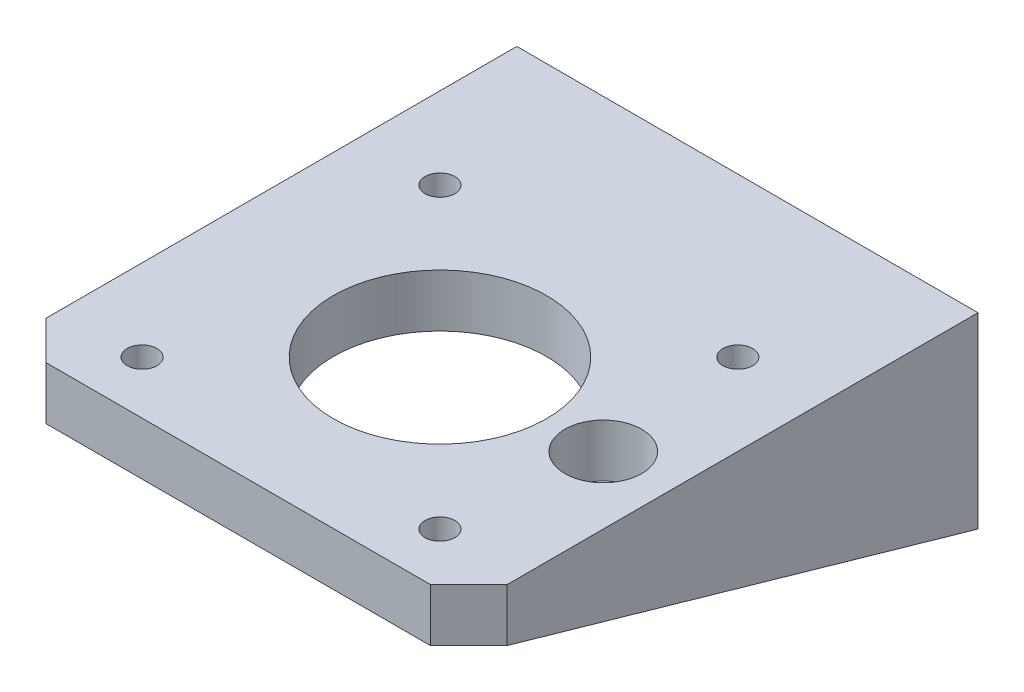
from build123d import *

# Parameters (mm, degrees)
CROQUIS1_R                 = 1.55
CROQUIS1_R_2               = 11.1
CROQUIS1_R_3               = 4
SALIENTE_EXTRUIR1_DEPTH    = 5.5
SALIENTE_EXTRUIR2_DEPTH    = 5.5
SALIENTE_EXTRUIR3_DEPTH    = 3
SALIENTE_EXTRUIR4_DEPTH    = 5.5
SALIENTE_EXTRUIR5_DEPTH    = 3
CROQUIS7_W                 = 42
CROQUIS7_H                 = 9
SALIENTE_EXTRUIR6_DEPTH    = 14
CROQUIS9_R                 = 1.55
CORTAR_EXTRUIR1_DEPTH      = 9
CROQUIS10_R                = 2.85
CROQUIS10_R_2              = 1.55
CORTAR_EXTRUIR2_DEPTH      = 3
CORTAR_EXTRUIR3_DEPTH      = 4
CORTAR_EXTRUIR3_DEPTH_BACK = 46


with BuildPart() as part:
    # Croquis1 → Saliente-Extruir1 (new body)
    with BuildSketch(Plane(origin=(0, 0, 0), x_dir=(1, 0, 0), z_dir=(0, 1, 0))):
        Polygon((0, 4), (0, 49), (4, 53), (44, 53), (48, 49), (48, 4), (44, 0), (4, 0), align=None)
        with Locations((8.5, 36.5)):
            Circle(CROQUIS1_R, mode=Mode.SUBTRACT)
        with Locations((39.5, 36.5)):
            Circle(CROQUIS1_R, mode=Mode.SUBTRACT)
        with Locations((8.5, 5.5)):
            Circle(CROQUIS1_R, mode=Mode.SUBTRACT)
        with Locations((39.5, 5.5)):
            Circle(CROQUIS1_R, mode=Mode.SUBTRACT)
        with Locations((24, 21)):
            Circle(CROQUIS1_R_2, mode=Mode.SUBTRACT)
        with Locations((41, 21)):
            Circle(CROQUIS1_R_3, mode=Mode.SUBTRACT)
    extrude(amount=SALIENTE_EXTRUIR1_DEPTH)

    # Croquis3 → Saliente-Extruir2 (add)
    with BuildSketch(Plane(origin=(0, 5.5, 0), x_dir=(1, 0, 0), z_dir=(0, 1, 0))):
        Polygon((4, 53), (0, 53), (0, 49), align=None)
    extrude(amount=-SALIENTE_EXTRUIR2_DEPTH)

    # Croquis4 → Saliente-Extruir3 (add)
    with BuildSketch(Plane.ZY):
        Polygon((-53, 0), (-53, 5.5), (-4, 5.5), (-4, 0), (-53, -14), align=None)
    extrude(amount=-SALIENTE_EXTRUIR3_DEPTH)

    # Croquis5 → Saliente-Extruir4 (add)
    with BuildSketch(Plane(origin=(0, 5.5, 0), x_dir=(1, 0, 0), z_dir=(0, 1, 0))):
        Polygon((48, 49), (48, 53), (44, 53), align=None)
    extrude(amount=-SALIENTE_EXTRUIR4_DEPTH)

    # Croquis6 → Saliente-Extruir5 (add)
    with BuildSketch(Plane(origin=(48, 0, 0), x_dir=(0, 0, -1), z_dir=(1, 0, 0))):
        Polygon((4, 5.5), (4, 0), (53, -14), (53, 0), (53, 5.5), align=None)
    extrude(amount=-SALIENTE_EXTRUIR5_DEPTH)

    # Croquis7 → Saliente-Extruir6 (add)
    with BuildSketch(Plane.XZ):
        with Locations((24, -48.5)):
            Rectangle(CROQUIS7_W, CROQUIS7_H)
    extrude(amount=SALIENTE_EXTRUIR6_DEPTH)

    # Croquis9 → Cortar-Extruir1 (cut)
    with BuildSketch(Plane.XY.offset(-44)):
        with Locations((9, -5.714285714)):
            Circle(CROQUIS9_R)
        with Locations((39, -5.714285714)):
            Circle(CROQUIS9_R)
    extrude(amount=-CORTAR_EXTRUIR1_DEPTH, mode=Mode.SUBTRACT)

    # Croquis10 → Cortar-Extruir2 (cut)
    with BuildSketch(Plane.XY.offset(-44)):
        with Locations((9, -5.714285714)):
            Circle(CROQUIS10_R)
        with Locations((9, -5.714285714)):
            Circle(CROQUIS10_R_2, mode=Mode.SUBTRACT)
        with Locations((39, -5.714285714)):
            Circle(CROQUIS10_R)
        with Locations((39, -5.714285714)):
            Circle(CROQUIS10_R_2, mode=Mode.SUBTRACT)
    extrude(amount=-CORTAR_EXTRUIR2_DEPTH, mode=Mode.SUBTRACT)

    # Croquis11 → Cortar-Extruir3 (cut, two sides)
    with BuildSketch(Plane.ZY.offset(-3)) as cortar_extruir3_sk:
        Polygon((-44, -11.428571429), (-53, -14), (-44, -14), align=None)
    extrude(amount=CORTAR_EXTRUIR3_DEPTH, mode=Mode.SUBTRACT)
    extrude(cortar_extruir3_sk.sketch, amount=-CORTAR_EXTRUIR3_DEPTH_BACK, mode=Mode.SUBTRACT)


solid = part.part
